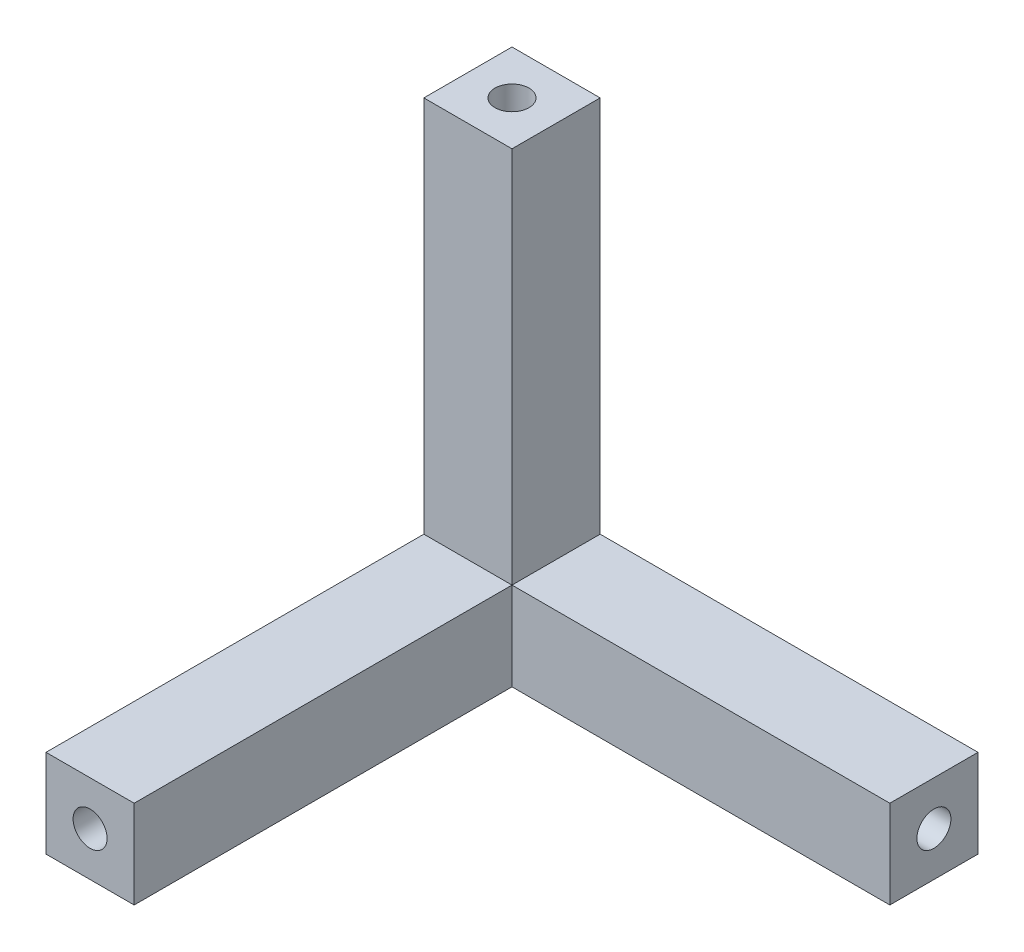
from build123d import *

# Parameters (mm, degrees)
BOSS_EXTRUDE1_DEPTH  = 1.75
SKETCH3_R            = 0.675
CUT_EXTRUDE1_DEPTH   = 15
SKETCH4_R            = 0.675
CUT_EXTRUDE2_DEPTH   = 15
SKETCH5_W            = 3.5
SKETCH5_H            = 3.5
CUT_SWEEP1_PROFILE_R = 0.675


with BuildPart() as part:
    # Sketch2 → Boss-Extrude1 (new, symmetric)
    with BuildSketch(Plane(origin=(0, 0, 0), x_dir=(1, 0, 0), z_dir=(0, 1, 0))):
        Polygon((-1.75, 1.75), (-1.75, -16.75), (1.75, -16.75), (1.75, -1.75), (16.75, -1.75), (16.75, 1.75), align=None)
    extrude(amount=BOSS_EXTRUDE1_DEPTH, both=True)

    # Sketch3 → Cut-Extrude1 (cut)
    with BuildSketch(Plane.XY.offset(16.75)):
        Circle(SKETCH3_R)
    extrude(amount=-CUT_EXTRUDE1_DEPTH, mode=Mode.SUBTRACT)

    # Sketch4 → Cut-Extrude2 (cut)
    with BuildSketch(Plane(origin=(16.75, 0, 0), x_dir=(0, 0, -1), z_dir=(1, 0, 0))):
        Circle(SKETCH4_R)
    extrude(amount=-CUT_EXTRUDE2_DEPTH, mode=Mode.SUBTRACT)

    # Sweep1: sweep along a path in Sketch7
    with BuildLine(Plane(origin=(0, 0, 0), x_dir=(0.7071067811865477, 0, 0.7071067811865475), z_dir=(-0.7071067811865475, 0, 0.7071067811865477))) as sweep1_path:
        Line((0, 1.75), (0, 16.75))
    # Sketch5 → Sweep1 (sweep)
    with BuildSketch(Plane(origin=(0, 1.75, 0), x_dir=(1, 0, 0), z_dir=(0, 1, 0))):
        Rectangle(SKETCH5_W, SKETCH5_H)
    sweep(path=sweep1_path.line)

    # Cut-Sweep1: sweep along a path in Sketch7_2
    with BuildLine(Plane(origin=(0, 0, 0), x_dir=(0.7071067811865477, 0, 0.7071067811865475), z_dir=(-0.7071067811865475, 0, 0.7071067811865477))) as cut_sweep1_path:
        Line((0, 1.75), (0, 16.75))
    # Cut-Sweep1 profile (on start of the path) → Cut-Sweep1 (sweep, cut)
    with BuildSketch(Plane(origin=(0, 1.75, 0), x_dir=(1, 0, 0), z_dir=(0, 1, 0))):
        Circle(CUT_SWEEP1_PROFILE_R)
    sweep(path=cut_sweep1_path.line, mode=Mode.SUBTRACT)


solid = part.part
